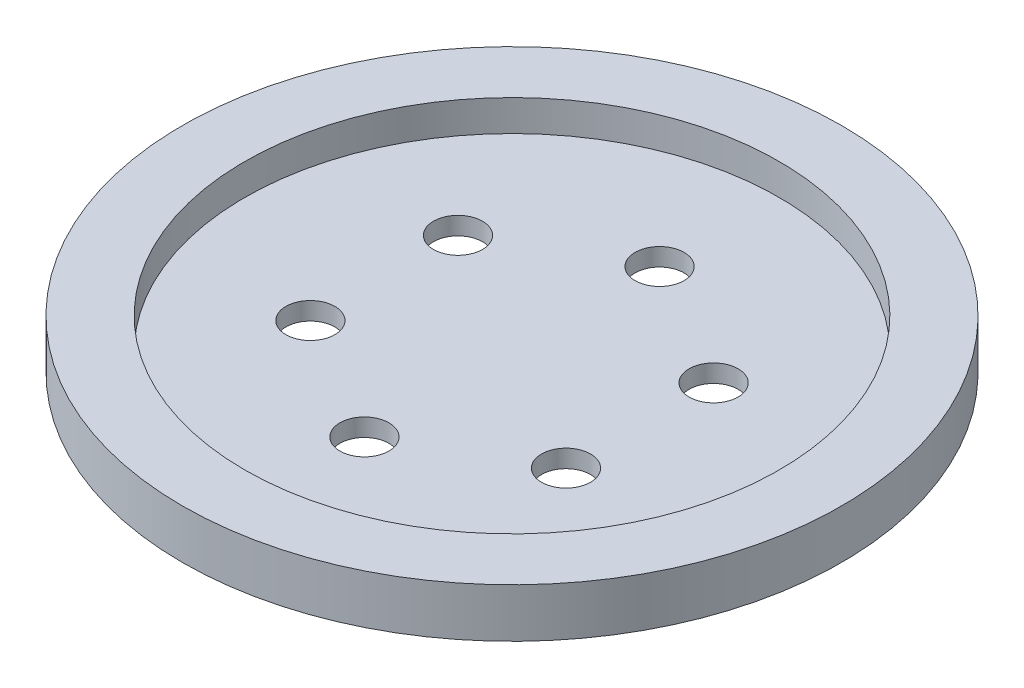
from build123d import *

# Parameters (mm, degrees)
SKETCH1_R           = 37
SKETCH1_R_2         = 2.75
BOSS_EXTRUDE1_DEPTH = 2
SKETCH2_R           = 37
SKETCH2_R_2         = 30
BOSS_EXTRUDE2_DEPTH = 3.5


with BuildPart() as part:
    # Sketch1 → Boss-Extrude1 (new body)
    with BuildSketch(Plane(origin=(0, 0, 0), x_dir=(1, 0, 0), z_dir=(0, 1, 0))):
        Circle(SKETCH1_R)
        with Locations((0, 16.57)):
            Circle(SKETCH1_R_2, mode=Mode.SUBTRACT)
        with Locations((-14.350040941, 8.285)):
            Circle(SKETCH1_R_2, mode=Mode.SUBTRACT)
        with Locations((-14.350040941, -8.285)):
            Circle(SKETCH1_R_2, mode=Mode.SUBTRACT)
        with Locations((0, -16.57)):
            Circle(SKETCH1_R_2, mode=Mode.SUBTRACT)
        with Locations((14.350040941, -8.285)):
            Circle(SKETCH1_R_2, mode=Mode.SUBTRACT)
        with Locations((14.350040941, 8.285)):
            Circle(SKETCH1_R_2, mode=Mode.SUBTRACT)
    extrude(amount=BOSS_EXTRUDE1_DEPTH)

    # Sketch2 → Boss-Extrude2 (add)
    with BuildSketch(Plane(origin=(0, 2, 0), x_dir=(1, 0, 0), z_dir=(0, 1, 0))):
        Circle(SKETCH2_R)
        Circle(SKETCH2_R_2, mode=Mode.SUBTRACT)
    extrude(amount=BOSS_EXTRUDE2_DEPTH)


solid = part.part
